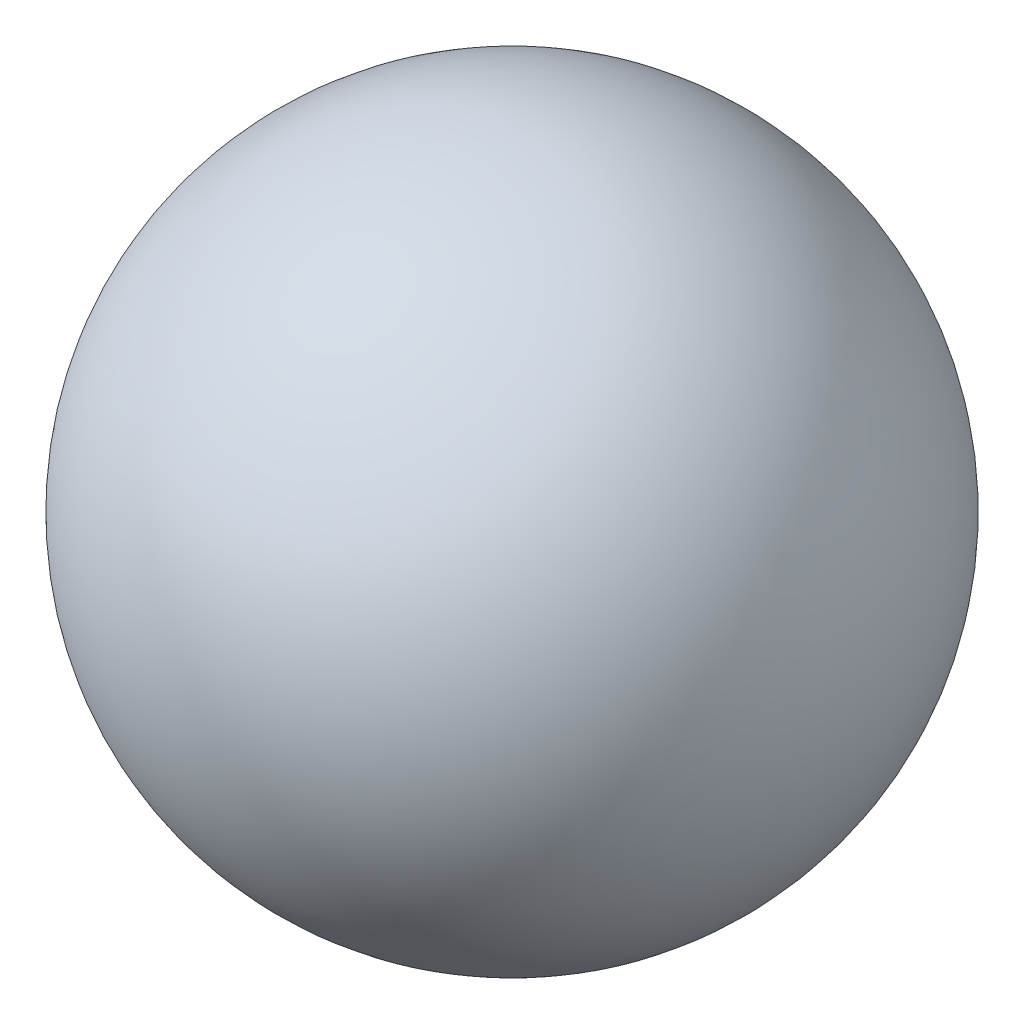
from build123d import *


with BuildPart() as part:
    # Esquisse1 → Révolution1 (revolve)
    with BuildSketch(Plane.XY):
        with BuildLine():
            Line((0, 30), (0, -30))
            ThreePointArc((0, -30), (-30, 0), (0, 30))
        make_face()
    revolve(axis=Axis((0, 30, 0), (0, -1, 0)))


solid = part.part
